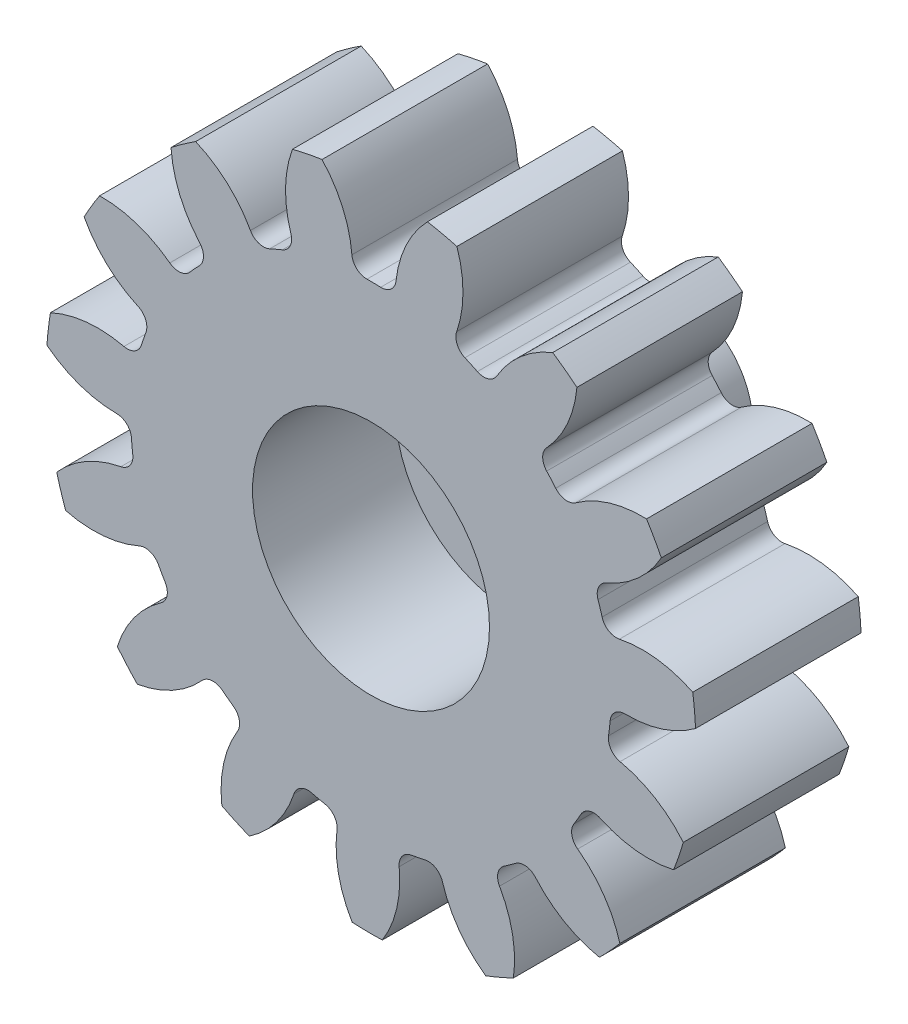
from build123d import *

# Parameters (mm, degrees)
SKETCH3_R          = 21.59
GEARBODY_DEPTH     = 11
TOOTHCUT_DEPTH     = 12
CIRPATTERN1_COUNT  = 15
BOREDIA_R          = 7.874
BORE_DEPTH         = 12700
SKETCH6_R          = 4.1
CUT_EXTRUDE1_DEPTH = 5.3


with BuildPart() as part:
    # Sketch3 → gearBody (new body)
    with BuildSketch(Plane.XY):
        Circle(SKETCH3_R)
    extrude(amount=GEARBODY_DEPTH)

    # Sketch2 → toothCut (cut, through all)
    with BuildSketch(Plane.XY):
        with BuildLine():
            ThreePointArc((15.783846764, -2.304552616), (15.843293638, -1.852249483), (15.889781974, -1.39843136))
            ThreePointArc((15.889781974, -1.39843136), (16.213055843, -0.751556907), (16.890861518, -0.499501321))
            ThreePointArc((16.890861518, -0.499501321), (20.504912911, 0.340315353), (23.283949955, 2.798691365))
            ThreePointArc((23.283949955, 2.798691365), (23.292901215, -2.723187818), (22.010467945, -8.09409042))
            ThreePointArc((22.010467945, -8.09409042), (19.873444675, -5.060974685), (16.550574786, -3.410158156))
            ThreePointArc((16.550574786, -3.410158156), (15.949189176, -3.008551507), (15.783846764, -2.304552616))
        make_face()
    toothcut = extrude(amount=TOOTHCUT_DEPTH, mode=Mode.SUBTRACT)

    # CirPattern1: toothCut ×15 about axis
    cirpattern1_axis = Axis((0, 0, 0), (0, 0, 1))
    for i in range(1, CIRPATTERN1_COUNT):
        add(toothcut.rotate(cirpattern1_axis, i * 360 / CIRPATTERN1_COUNT), mode=Mode.SUBTRACT)

    # boreDia → bore (cut, symmetric)
    with BuildSketch(Plane.XY):
        Circle(BOREDIA_R)
    extrude(amount=BORE_DEPTH, both=True, mode=Mode.SUBTRACT)

    # Sketch4 → Revolve1 (revolve)
    with BuildSketch(Plane(origin=(0, 0, 0), x_dir=(0, 0, -1), z_dir=(1, 0, 0))):
        with BuildLine():
            Line((0, 0), (9.525, 0))
            Line((9.525, 0), (9.525, 4.826))
            Line((9.525, 4.826), (5.588, 4.826))
            ThreePointArc((5.588, 4.826), (1.636687307, 6.462687307), (0, 10.414))
            Line((0, 10.414), (0, 7.874))
            Line((0, 7.874), (-1.524, 7.874))
            Line((-1.524, 7.874), (-1.524, 0))
            Line((-1.524, 0), (0, 0))
        make_face()
    revolve(axis=Axis((0, 0, 0), (0, 0, -1)))

    # Sketch6 → Cut-Extrude1 (cut)
    with BuildSketch(Plane(origin=(0, 0, -9.525), x_dir=(-1, 0, 0), z_dir=(0, 0, -1))):
        Circle(SKETCH6_R)
    extrude(amount=-CUT_EXTRUDE1_DEPTH, mode=Mode.SUBTRACT)


solid = part.part
